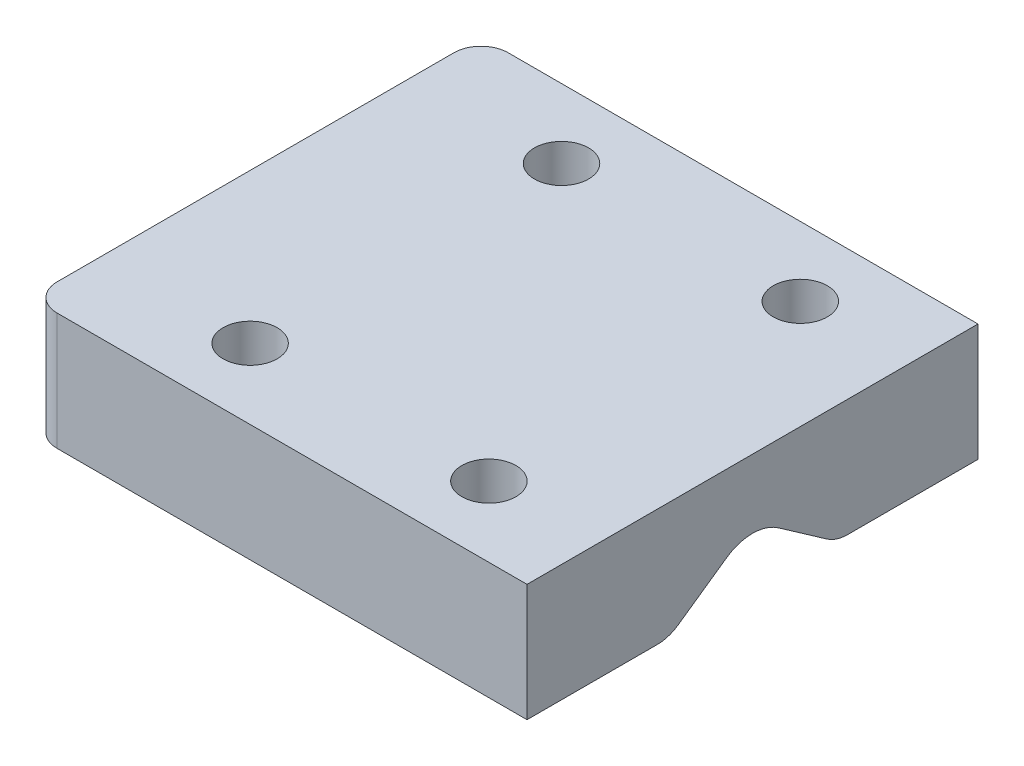
from build123d import *

# Parameters (mm, degrees)
SKETCH6_W          = 55.097235346
SKETCH6_H          = 50
MAIN_BODY_DEPTH    = 13
MAIN_HOLE_DEPTH    = 56.097235346
EXTERIOR_FILLET_R  = 3
SKETCH9_R          = 3
BOLT_HOLES_DEPTH   = 14
TOP_HOLE_FILLET_R  = 5
SIDE_HOLE_FILLET_R = 4


with BuildPart() as part:
    # Sketch6 → Main Body (new body)
    with BuildSketch(Plane(origin=(0, 68, 0), x_dir=(1, 0, 0), z_dir=(0, 1, 0))):
        with Locations((-0.048617673, 0)):
            Rectangle(SKETCH6_W, SKETCH6_H)
    extrude(amount=MAIN_BODY_DEPTH)

    # Sketch7 → Main Hole (cut, through all)
    with BuildSketch(Plane(origin=(27.5, 0, 0), x_dir=(0, 0, -1), z_dir=(1, 0, 0))):
        Polygon((0, 74.5), (-9.282962044, 68), (0, 61.5), (9.282962044, 68), align=None)
    extrude(amount=-MAIN_HOLE_DEPTH, mode=Mode.SUBTRACT)

    # Exterior Fillet
    exterior_fillet_edges = [part.edges().sort_by_distance(p)[0] for p in [
        (-27.597235346, 74.5, 25),
        (-27.597235346, 74.5, -25),
    ]]
    fillet(exterior_fillet_edges, radius=EXTERIOR_FILLET_R)

    # Sketch9 → Bolt Holes (cut, through all)
    with BuildSketch(Plane(origin=(0, 81, 0), x_dir=(1, 0, 0), z_dir=(0, 1, 0))):
        with Locations((15.473743703, -17.201232435)):
            Circle(SKETCH9_R)
        with Locations((-11, -17.201232435)):
            Circle(SKETCH9_R)
        with Locations((15.473743703, 17.324336932)):
            Circle(SKETCH9_R)
        with Locations((-11, 17.324336932)):
            Circle(SKETCH9_R)
    extrude(amount=-BOLT_HOLES_DEPTH, mode=Mode.SUBTRACT)

    # Top Hole Fillet
    top_hole_fillet_edges = [part.edges().sort_by_distance(p)[0] for p in [
        (-0.048617673, 74.5, 0),
    ]]
    fillet(top_hole_fillet_edges, radius=TOP_HOLE_FILLET_R)

    # Side Hole Fillet
    side_hole_fillet_edges = [part.edges().sort_by_distance(p)[0] for p in [
        (-0.048617673, 68, -9.282962044),
        (-0.048617673, 68, 9.282962044),
    ]]
    fillet(side_hole_fillet_edges, radius=SIDE_HOLE_FILLET_R)


solid = part.part
